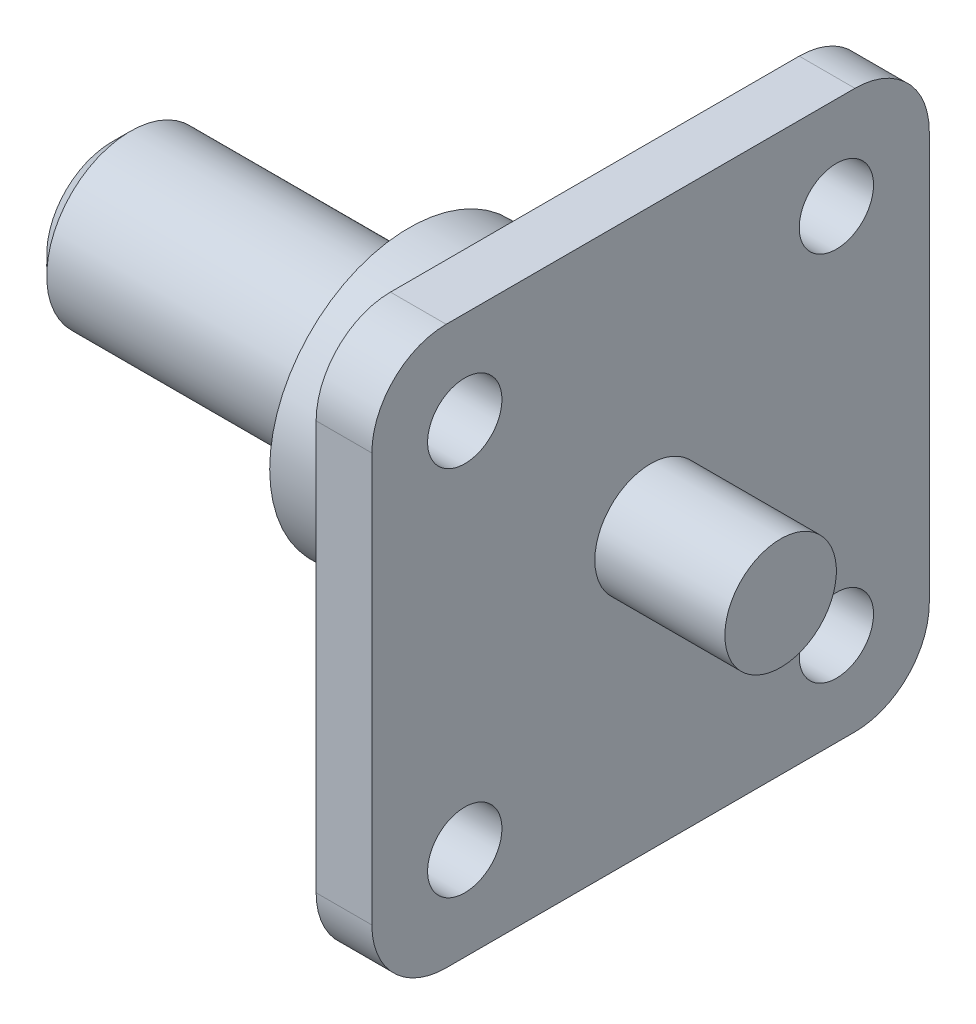
from build123d import *

# Parameters (mm, degrees)
REDONDEO1_R             = 1
CHAFL_N1_SIZE           = 1
CROQUIS2_R              = 2
SALIENTE_EXTRUIR1_DEPTH = 3


with BuildPart() as part:
    # Croquis1 → Revolución1 (revolve)
    with BuildSketch(Plane.XY):
        Polygon((-16, 0), (-16, 4.5), (0, 4.5), (0, 7.5), (10, 7.5), (10, 3), (20, 3), (20, 0), align=None)
    revolve(axis=Axis((-18.371134021, 0, 0), (1, 0, 0)))

    # Redondeo1
    redondeo1_edges = [part.edges().sort_by_distance(p)[0] for p in [
        (0, -4.5, 0),
    ]]
    fillet(redondeo1_edges, radius=REDONDEO1_R)

    # Chaflán1
    chafl_n1_edges = [part.edges().sort_by_distance(p)[0] for p in [
        (-16, -4.5, 0),
    ]]
    chamfer(chafl_n1_edges, length=CHAFL_N1_SIZE)

    # Croquis2 → Saliente-Extruir1 (add)
    with BuildSketch(Plane(origin=(10, 0, 0), x_dir=(0, 0, -1), z_dir=(1, 0, 0))):
        with BuildLine():
            Line((-11, -15), (11, -15))
            ThreePointArc((11, -15), (13.828427125, -13.828427125), (15, -11))
            Line((15, -11), (15, 11))
            ThreePointArc((15, 11), (13.828427125, 13.828427125), (11, 15))
            Line((11, 15), (-11, 15))
            ThreePointArc((-11, 15), (-13.828427125, 13.828427125), (-15, 11))
            Line((-15, 11), (-15, -11))
            ThreePointArc((-15, -11), (-13.828427125, -13.828427125), (-11, -15))
        make_face()
        with Locations((-10, 10)):
            Circle(CROQUIS2_R, mode=Mode.SUBTRACT)
        with Locations((10, 10)):
            Circle(CROQUIS2_R, mode=Mode.SUBTRACT)
        with Locations((10, -10)):
            Circle(CROQUIS2_R, mode=Mode.SUBTRACT)
        with Locations((-10, -10)):
            Circle(CROQUIS2_R, mode=Mode.SUBTRACT)
    extrude(amount=SALIENTE_EXTRUIR1_DEPTH)


solid = part.part
